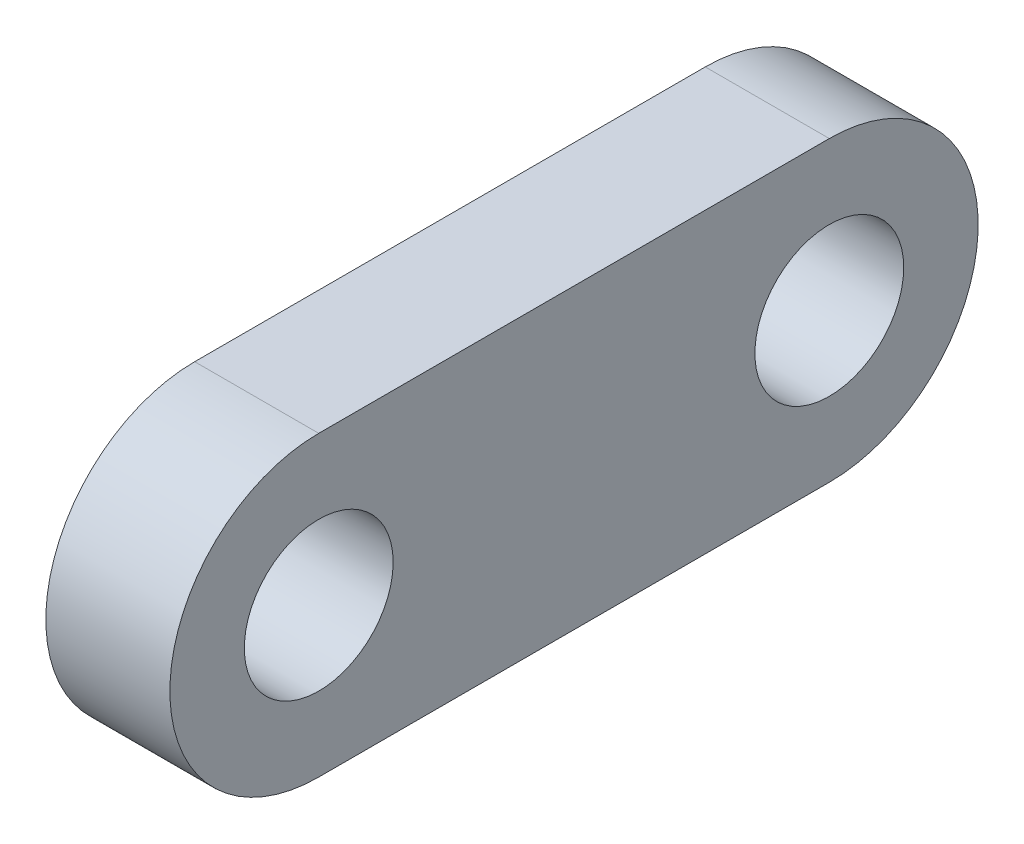
from build123d import *

# Parameters (mm, degrees)
ESBO_O1_R                = 3
RESSALTO_EXTRUS_O1_DEPTH = 5


with BuildPart() as part:
    # Esboço1 → Ressalto-extrusão1 (new body)
    with BuildSketch(Plane(origin=(0, 0, 0), x_dir=(0, 0, -1), z_dir=(1, 0, 0))):
        with BuildLine():
            Line((-21.434877193, 6), (-0.854877193, 6))
            ThreePointArc((-0.854877193, 6), (5.145122807, 0), (-0.854877193, -6))
            Line((-0.854877193, -6), (-21.434877193, -6))
            ThreePointArc((-21.434877193, -6), (-27.434877193, 0), (-21.434877193, 6))
        make_face()
        with Locations((-21.434877193, 0)):
            Circle(ESBO_O1_R, mode=Mode.SUBTRACT)
        with Locations((-0.854877193, 0)):
            Circle(ESBO_O1_R, mode=Mode.SUBTRACT)
    extrude(amount=RESSALTO_EXTRUS_O1_DEPTH)


solid = part.part
